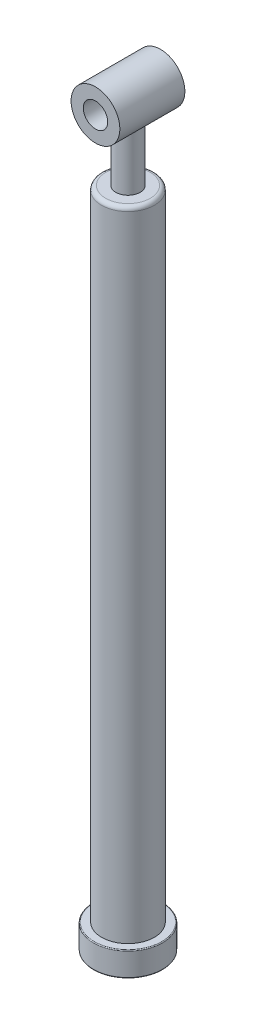
from build123d import *

# Parameters (mm, degrees)
SKETCH1_R                = 32.5
BOSS_EXTRUDE1_DEPTH      = 392.5
FILLET1_R                = 5
SKETCH2_R                = 42.5
BOSS_EXTRUDE2_DEPTH      = 30
SKETCH3_R                = 20
CUT_EXTRUDE1_DEPTH       = 810
SKETCH4_R                = 30
SKETCH4_R_2              = 15
BOSS_EXTRUDE3_DEPTH      = 40
BOSS_EXTRUDE4_REACH      = 819.213
BOSS_EXTRUDE4_END_RADIUS = 30
SKETCH5_R                = 15
FILLET2_R                = 1


with BuildPart() as part:
    # Sketch1 → Boss-Extrude1 (new, symmetric)
    with BuildSketch(Plane(origin=(0, 0, 0), x_dir=(1, 0, 0), z_dir=(0, 1, 0))):
        with Locations(Location((0, 0, 0), (0, 0, 270))):
            Circle(SKETCH1_R)
    extrude(amount=BOSS_EXTRUDE1_DEPTH, both=True)

    # Fillet1
    fillet1_edges = [part.edges().sort_by_distance(p)[0] for p in [
        (0, 392.5, -32.5),
    ]]
    fillet(fillet1_edges, radius=FILLET1_R)

    # Sketch2 → Boss-Extrude2 (add)
    with BuildSketch(Plane.XZ.offset(392.5)):
        with Locations(Location((0, 0, 0), (0, 0, 270))):
            Circle(SKETCH2_R)
    extrude(amount=BOSS_EXTRUDE2_DEPTH)

    # Sketch3 → Cut-Extrude1 (cut)
    with BuildSketch(Plane.XZ.offset(422.5)):
        with Locations(Location((0, 0, 0), (0, 0, 270))):
            Circle(SKETCH3_R)
    extrude(amount=-CUT_EXTRUDE1_DEPTH, mode=Mode.SUBTRACT)



with BuildPart() as body_2:
    # Sketch4 → Boss-Extrude3 (new, symmetric)
    with BuildSketch(Plane.XY):
        with Locations((0, 487.5)):
            Circle(SKETCH4_R)
        with Locations((0, 487.5)):
            Circle(SKETCH4_R_2, mode=Mode.SUBTRACT)
    extrude(amount=BOSS_EXTRUDE3_DEPTH, both=True)


with BuildPart() as part_1:
    add(part.part)

    add(body_2.part)  # Boss-Extrude4 merges body 2
    # Boss-Extrude4: up to this cylinder (the profile starts outside it)
    boss_extrude4_end = Plane(origin=(0, 487.5, 0), z_dir=(0, 0, -1)) * Cylinder(BOSS_EXTRUDE4_END_RADIUS, 1699.426, mode=Mode.PRIVATE)
    # Sketch5 → Boss-Extrude4 (add, up to the surface)
    with BuildSketch(Plane(origin=(0, 392.5, 0), x_dir=(1, 0, 0), z_dir=(0, 1, 0)), mode=Mode.PRIVATE) as boss_extrude4_sk1:
        with Locations(Location((0, 0, 0), (0, 0, 90))):
            Circle(SKETCH5_R)
    boss_extrude4_tool1 = extrude(boss_extrude4_sk1.sketch, amount=BOSS_EXTRUDE4_REACH, mode=Mode.PRIVATE) - boss_extrude4_end
    add(boss_extrude4_tool1.solids().sort_by_distance((0, 392.5, 0))[0])

    # Fillet2
    fillet2_edges = [part_1.edges().sort_by_distance(p)[0] for p in [
        (0, -392.5, 42.5),
        (0, -422.5, 42.5),
    ]]
    fillet(fillet2_edges, radius=FILLET2_R)


solid = part_1.part
